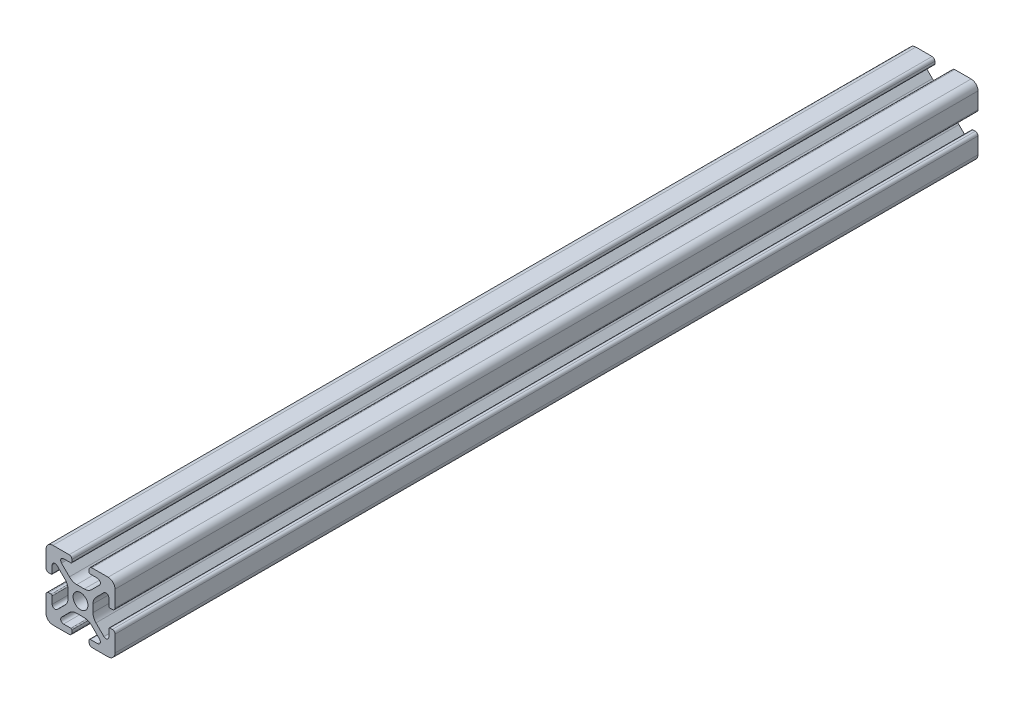
from build123d import *

# Parameters (mm, degrees)
SKETCH3_R                = 2.15
BOSS_EXTRUDE1_DEPTH      = 125
BOSS_EXTRUDE1_DEPTH_BACK = 125


with BuildPart() as part:
    # Sketch3 → Boss-Extrude1 (new body, two sides)
    with BuildSketch(Plane.XY) as boss_extrude1_sk:
        with BuildLine():
            Line((3.2874, 10), (8, 10))
            ThreePointArc((8, 10), (9.414213562, 9.414213562), (10, 8))
            Line((10, 8), (10, 3.2874))
            ThreePointArc((10, 3.2874), (9.76937588, 2.73062412), (9.2126, 2.5))
            Line((9.2126, 2.5), (8.5048, 2.5))
            ThreePointArc((8.5048, 2.5), (8.289273853, 2.589273853), (8.2, 2.8048))
            Line((8.2, 2.8048), (8.2, 4.9118))
            ThreePointArc((8.2, 4.9118), (7.682565253, 5.686195824), (6.769103096, 5.504496904))
            Line((6.769103096, 5.504496904), (4.478679656, 3.214073464))
            ThreePointArc((4.478679656, 3.214073464), (3.828361402, 2.240803418), (3.6, 1.092753121))
            Line((3.6, 1.092753121), (3.6, -1.092753121))
            ThreePointArc((3.6, -1.092753121), (3.828361402, -2.240803418), (4.478679656, -3.214073464))
            Line((4.478679656, -3.214073464), (6.769103096, -5.504496904))
            ThreePointArc((6.769103096, -5.504496904), (7.682565253, -5.686195824), (8.2, -4.9118))
            Line((8.2, -4.9118), (8.2, -2.8048))
            ThreePointArc((8.2, -2.8048), (8.289273853, -2.589273853), (8.5048, -2.5))
            Line((8.5048, -2.5), (9.2126, -2.5))
            ThreePointArc((9.2126, -2.5), (9.76937588, -2.73062412), (10, -3.2874))
            Line((10, -3.2874), (10, -8))
            ThreePointArc((10, -8), (9.414213562, -9.414213562), (8, -10))
            Line((8, -10), (3.2874, -10))
            ThreePointArc((3.2874, -10), (2.73062412, -9.76937588), (2.5, -9.2126))
            Line((2.5, -9.2126), (2.5, -8.5048))
            ThreePointArc((2.5, -8.5048), (2.589273853, -8.289273853), (2.8048, -8.2))
            Line((2.8048, -8.2), (4.9118, -8.2))
            ThreePointArc((4.9118, -8.2), (5.686195824, -7.682565253), (5.504496904, -6.769103096))
            Line((5.504496904, -6.769103096), (3.214073464, -4.478679656))
            ThreePointArc((3.214073464, -4.478679656), (2.240803418, -3.828361402), (1.092753121, -3.6))
            Line((1.092753121, -3.6), (-1.092753121, -3.6))
            ThreePointArc((-1.092753121, -3.6), (-2.240803418, -3.828361402), (-3.214073464, -4.478679656))
            Line((-3.214073464, -4.478679656), (-5.504496904, -6.769103096))
            ThreePointArc((-5.504496904, -6.769103096), (-5.686195824, -7.682565253), (-4.9118, -8.2))
            Line((-4.9118, -8.2), (-2.8048, -8.2))
            ThreePointArc((-2.8048, -8.2), (-2.589273853, -8.289273853), (-2.5, -8.5048))
            Line((-2.5, -8.5048), (-2.5, -9.2126))
            ThreePointArc((-2.5, -9.2126), (-2.73062412, -9.76937588), (-3.2874, -10))
            Line((-3.2874, -10), (-8, -10))
            ThreePointArc((-8, -10), (-9.414213562, -9.414213562), (-10, -8))
            Line((-10, -8), (-10, -3.2874))
            ThreePointArc((-10, -3.2874), (-9.76937588, -2.73062412), (-9.2126, -2.5))
            Line((-9.2126, -2.5), (-8.5048, -2.5))
            ThreePointArc((-8.5048, -2.5), (-8.289273853, -2.589273853), (-8.2, -2.8048))
            Line((-8.2, -2.8048), (-8.2, -4.9118))
            ThreePointArc((-8.2, -4.9118), (-7.682565253, -5.686195824), (-6.769103096, -5.504496904))
            Line((-6.769103096, -5.504496904), (-4.478679656, -3.214073464))
            ThreePointArc((-4.478679656, -3.214073464), (-3.828361402, -2.240803418), (-3.6, -1.092753121))
            Line((-3.6, -1.092753121), (-3.6, 1.092753121))
            ThreePointArc((-3.6, 1.092753121), (-3.828361402, 2.240803418), (-4.478679656, 3.214073464))
            Line((-4.478679656, 3.214073464), (-6.769103096, 5.504496904))
            ThreePointArc((-6.769103096, 5.504496904), (-7.682565253, 5.686195824), (-8.2, 4.9118))
            Line((-8.2, 4.9118), (-8.2, 2.8048))
            ThreePointArc((-8.2, 2.8048), (-8.289273853, 2.589273853), (-8.5048, 2.5))
            Line((-8.5048, 2.5), (-9.2126, 2.5))
            ThreePointArc((-9.2126, 2.5), (-9.76937588, 2.73062412), (-10, 3.2874))
            Line((-10, 3.2874), (-10, 8))
            ThreePointArc((-10, 8), (-9.414213562, 9.414213562), (-8, 10))
            Line((-8, 10), (-3.2874, 10))
            ThreePointArc((-3.2874, 10), (-2.73062412, 9.76937588), (-2.5, 9.2126))
            Line((-2.5, 9.2126), (-2.5, 8.5048))
            ThreePointArc((-2.5, 8.5048), (-2.589273853, 8.289273853), (-2.8048, 8.2))
            Line((-2.8048, 8.2), (-4.9118, 8.2))
            ThreePointArc((-4.9118, 8.2), (-5.686195824, 7.682565253), (-5.504496904, 6.769103096))
            Line((-5.504496904, 6.769103096), (-3.214073464, 4.478679656))
            ThreePointArc((-3.214073464, 4.478679656), (-2.240803418, 3.828361402), (-1.092753121, 3.6))
            Line((-1.092753121, 3.6), (1.092753121, 3.6))
            ThreePointArc((1.092753121, 3.6), (2.240803418, 3.828361402), (3.214073464, 4.478679656))
            Line((3.214073464, 4.478679656), (5.504496904, 6.769103096))
            ThreePointArc((5.504496904, 6.769103096), (5.686195824, 7.682565253), (4.9118, 8.2))
            Line((4.9118, 8.2), (2.8048, 8.2))
            ThreePointArc((2.8048, 8.2), (2.589273853, 8.289273853), (2.5, 8.5048))
            Line((2.5, 8.5048), (2.5, 9.2126))
            ThreePointArc((2.5, 9.2126), (2.73062412, 9.76937588), (3.2874, 10))
        make_face()
        Circle(SKETCH3_R, mode=Mode.SUBTRACT)
    extrude(amount=BOSS_EXTRUDE1_DEPTH)
    extrude(boss_extrude1_sk.sketch, amount=-BOSS_EXTRUDE1_DEPTH_BACK)


solid = part.part
